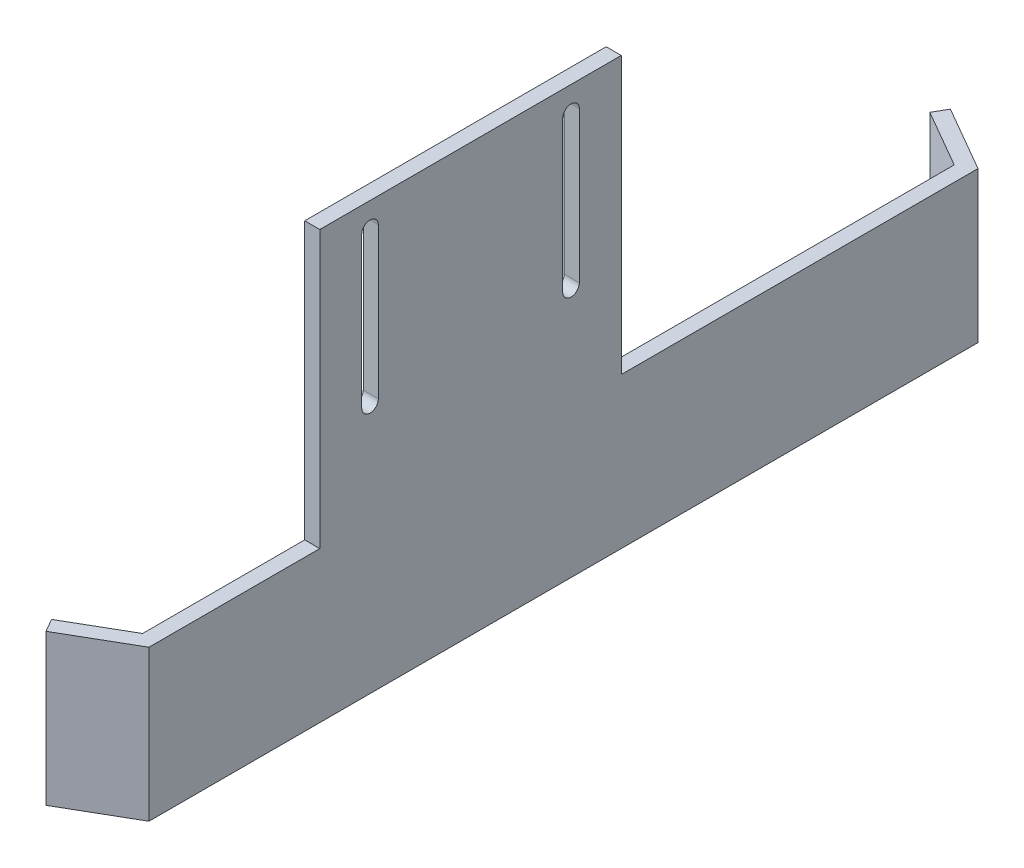
from build123d import *

# Parameters (mm, degrees)
ESQUISSE1_W                         = 85
ESQUISSE1_H                         = 10
ESQUISSE1_R                         = 1
BOSS_EXTRU_1_DEPTH                  = 3
ESQUISSE2_W                         = 165
ESQUISSE2_H                         = 65
BOSS_EXTRU_2_DEPTH                  = 3
ENL_V_MAT_EXTRU_1_REACH             = 87
ESQUISSE3_W                         = 34
ESQUISSE3_H                         = 35
ESQUISSE3_W_2                       = 71
BOSS_EXTRU_3_DEPTH                  = 10
BOSS_EXTRU_5_DEPTH                  = 30
ENL_V_MAT_EXTRU_2_REACH             = 87
ESQUISSE8_R                         = 1.65
ENL_V_MAT_EXTRU_2_DIRECTION_2_DEPTH = 1
ENL_V_MAT_EXTRU_3_DEPTH             = 8
ESQUISSE12_W                        = 95.226934881
ESQUISSE12_H                        = 85.849602385
ENL_V_MAT_EXTRU_4_DEPTH             = 66
ESQUISSE13_W                        = 60
ESQUISSE13_H                        = 20
BOSS_EXTRU_6_DEPTH                  = 3
ENL_V_MAT_EXTRU_5_DEPTH             = 3


with BuildPart() as part:
    # Esquisse1 → Boss.-Extru.1 (new body)
    with BuildSketch(Plane.XY):
        with Locations((42.5, 5)):
            Rectangle(ESQUISSE1_W, ESQUISSE1_H)
        with Locations((5, 5)):
            Circle(ESQUISSE1_R, mode=Mode.SUBTRACT)
    extrude(amount=BOSS_EXTRU_1_DEPTH)

    # Esquisse2 → Boss.-Extru.2 (add)
    with BuildSketch(Plane(origin=(85, 0, 0), x_dir=(0, 0, -1), z_dir=(1, 0, 0))):
        with Locations((17, -22.5)):
            Rectangle(ESQUISSE2_W, ESQUISSE2_H)
    extrude(amount=-BOSS_EXTRU_2_DEPTH)

    # Esquisse3 → Enlèv. mat.-Extru.1 (cut, up to next)
    with BuildSketch(Plane(origin=(85, 0, 0), x_dir=(0, 0, -1), z_dir=(1, 0, 0)), mode=Mode.PRIVATE) as enl_v_mat_extru_1_sk1:
        with Locations((-48.5, -7.5)):
            Rectangle(ESQUISSE3_W, ESQUISSE3_H)
    enl_v_mat_extru_1_tool1 = extrude(enl_v_mat_extru_1_sk1.sketch, amount=-ENL_V_MAT_EXTRU_1_REACH, mode=Mode.PRIVATE) & part.part
    add(enl_v_mat_extru_1_tool1.solids().sort_by_distance((85, -7.5, 48.5))[0], mode=Mode.SUBTRACT)
    # Esquisse3 → Enlèv. mat.-Extru.1 (cut, up to next)
    with BuildSketch(Plane(origin=(85, 0, 0), x_dir=(0, 0, -1), z_dir=(1, 0, 0)), mode=Mode.PRIVATE) as enl_v_mat_extru_1_sk2:
        with Locations((64, -7.5)):
            Rectangle(ESQUISSE3_W_2, ESQUISSE3_H)
    enl_v_mat_extru_1_tool2 = extrude(enl_v_mat_extru_1_sk2.sketch, amount=-ENL_V_MAT_EXTRU_1_REACH, mode=Mode.PRIVATE) & part.part
    add(enl_v_mat_extru_1_tool2.solids().sort_by_distance((85, -7.5, -64))[0], mode=Mode.SUBTRACT)

    # Esquisse5 → Boss.-Extru.3 (add)
    with BuildSketch(Plane(origin=(0, 10, 0), x_dir=(1, 0, 0), z_dir=(0, 1, 0))):
        Polygon((63.707714548, 0), (82, 28.5), (82, 0), align=None)
        Polygon((63.707714548, -3), (82, -3), (82, -31.5), align=None)
    extrude(amount=-BOSS_EXTRU_3_DEPTH)

    # Esquisse7 → Boss.-Extru.5 (add)
    with BuildSketch(Plane.XZ.offset(55)):
        Polygon((85, 65.5), (72.009618943, 73), (70.509618943, 70.401923789), (82, 63.767949192), align=None)
        Polygon((70.509618943, -104.401923789), (82, -97.767949192), (85, -99.5), (72.009618943, -107), align=None)
    extrude(amount=-BOSS_EXTRU_5_DEPTH)

    # Esquisse8 → Enlèv. mat.-Extru.2 (cut, up to next)
    with BuildSketch(Plane(origin=(85, 0, 0), x_dir=(0, 0, -1), z_dir=(1, 0, 0)), mode=Mode.PRIVATE) as enl_v_mat_extru_2_sk1:
        with Locations((-21.5, 5)):
            Circle(ESQUISSE8_R)
    enl_v_mat_extru_2_tool1 = extrude(enl_v_mat_extru_2_sk1.sketch, amount=-ENL_V_MAT_EXTRU_2_REACH, mode=Mode.PRIVATE) & part.part
    add(enl_v_mat_extru_2_tool1.solids().sort_by_distance((85, 5, 21.5))[0], mode=Mode.SUBTRACT)
    # Esquisse8 → Enlèv. mat.-Extru.2 (cut, up to next)
    with BuildSketch(Plane(origin=(85, 0, 0), x_dir=(0, 0, -1), z_dir=(1, 0, 0)), mode=Mode.PRIVATE) as enl_v_mat_extru_2_sk2:
        with Locations((18.5, 5)):
            Circle(ESQUISSE8_R)
    enl_v_mat_extru_2_tool2 = extrude(enl_v_mat_extru_2_sk2.sketch, amount=-ENL_V_MAT_EXTRU_2_REACH, mode=Mode.PRIVATE) & part.part
    add(enl_v_mat_extru_2_tool2.solids().sort_by_distance((85, 5, -18.5))[0], mode=Mode.SUBTRACT)

    # Esquisse8 → Enlèv. mat.-Extru.2 direction 2 (cut)
    with BuildSketch(Plane(origin=(85, 0, 0), x_dir=(0, 0, -1), z_dir=(1, 0, 0))):
        with Locations((-21.5, 5)):
            Circle(ESQUISSE8_R)
        with Locations((18.5, 5)):
            Circle(ESQUISSE8_R)
    extrude(amount=ENL_V_MAT_EXTRU_2_DIRECTION_2_DEPTH, mode=Mode.SUBTRACT)

    # Esquisse9 → Enlèv. mat.-Extru.3 (cut)
    with BuildSketch(Plane.ZY.offset(-72)):
        Polygon((-16.854551733, 7.85), (-20.145448267, 7.85), (-21.790896534, 5), (-20.145448267, 2.15), (-16.854551733, 2.15), (-15.209103466, 5), align=None)
        Polygon((23.145448267, 7.85), (19.854551733, 7.85), (18.209103466, 5), (19.854551733, 2.15), (23.145448267, 2.15), (24.790896534, 5), align=None)
    extrude(amount=-ENL_V_MAT_EXTRU_3_DEPTH, mode=Mode.SUBTRACT)

    # Esquisse12 → Enlèv. mat.-Extru.4 (cut, through all)
    with BuildSketch(Plane(origin=(0, 10, 0), x_dir=(1, 0, 0), z_dir=(0, 1, 0))):
        with Locations((34.386532559, 2.239892923)):
            Rectangle(ESQUISSE12_W, ESQUISSE12_H)
    extrude(amount=-ENL_V_MAT_EXTRU_4_DEPTH, mode=Mode.SUBTRACT)

    # Esquisse13 → Boss.-Extru.6 (add)
    with BuildSketch(Plane.ZY.offset(-82)):
        with Locations((1.5, 20)):
            Rectangle(ESQUISSE13_W, ESQUISSE13_H)
    extrude(amount=-BOSS_EXTRU_6_DEPTH)

    # Esquisse14 → Enlèv. mat.-Extru.5 (cut)
    with BuildSketch(Plane.ZY.offset(-82)):
        with BuildLine():
            Line((-20.15, -5), (-20.15, 25))
            ThreePointArc((-20.15, 25), (-18.5, 26.65), (-16.85, 25))
            Line((-16.85, 25), (-16.85, -5))
            ThreePointArc((-16.85, -5), (-18.5, -6.65), (-20.15, -5))
        make_face()
        with BuildLine():
            Line((19.85, -5), (19.85, 25))
            ThreePointArc((19.85, 25), (21.5, 26.65), (23.15, 25))
            Line((23.15, 25), (23.15, -5))
            ThreePointArc((23.15, -5), (21.5, -6.65), (19.85, -5))
        make_face()
    extrude(amount=-ENL_V_MAT_EXTRU_5_DEPTH, mode=Mode.SUBTRACT)


solid = part.part
